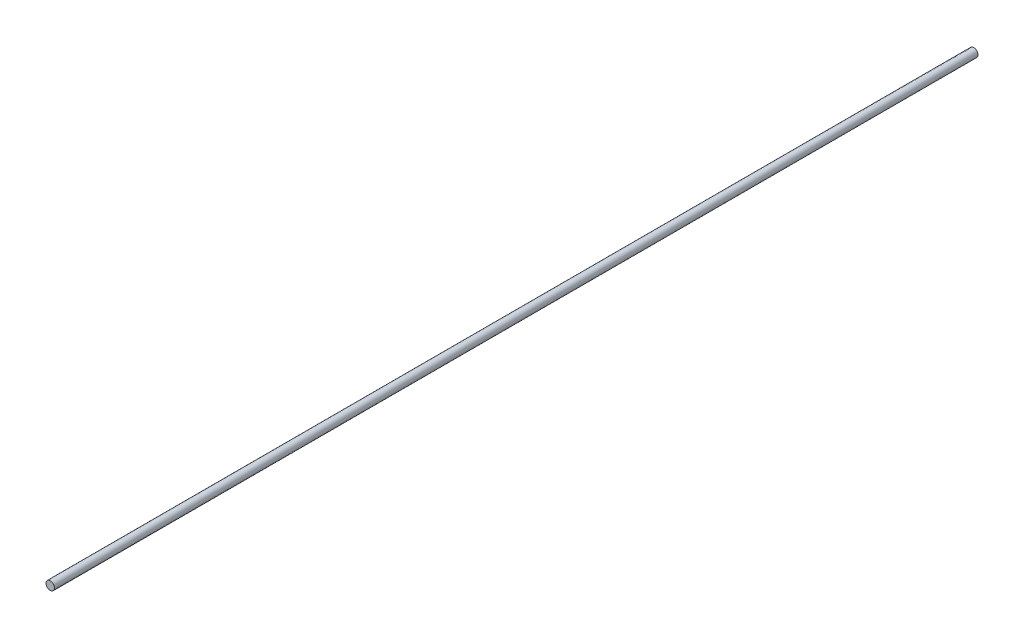
from build123d import *

# Parameters (mm, degrees)
SKETCH1_R           = 4
BOSS_EXTRUDE2_DEPTH = 875


with BuildPart() as part:
    # Sketch1 → Boss-Extrude2 (new body)
    with BuildSketch(Plane.XY):
        Circle(SKETCH1_R)
    extrude(amount=BOSS_EXTRUDE2_DEPTH)


solid = part.part
